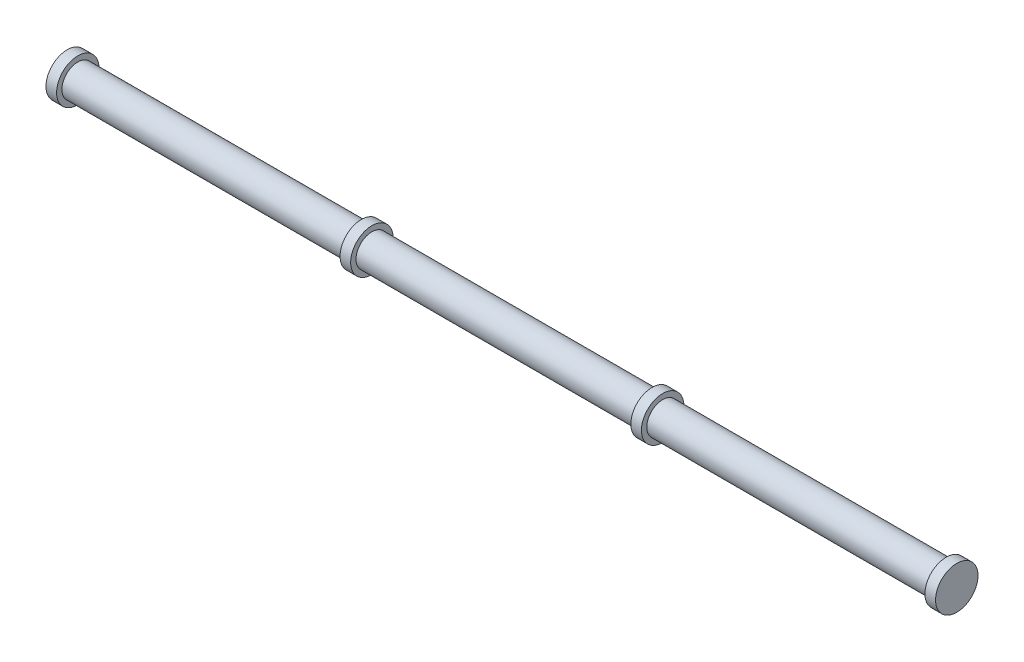
from build123d import *

# Parameters (mm, degrees)
SKETCH1_R           = 7.5
BOSS_EXTRUDE1_DEPTH = 204.47
SKETCH2_R           = 10
BOSS_EXTRUDE2_DEPTH = 5
SKETCH3_R           = 10
BOSS_EXTRUDE3_DEPTH = 2.5
SKETCH4_R           = 10
BOSS_EXTRUDE4_DEPTH = 2.5


with BuildPart() as part:
    # Sketch1 → Boss-Extrude1 (new body, symmetric)
    with BuildSketch(Plane(origin=(0, 0, 0), x_dir=(0, 0, -1), z_dir=(1, 0, 0))):
        Circle(SKETCH1_R)
    extrude(amount=BOSS_EXTRUDE1_DEPTH, both=True)


with BuildPart() as body_2:
    # Sketch2 → Boss-Extrude2 (new body)
    with BuildSketch(Plane(origin=(204.47, 0, 0), x_dir=(0, 0, -1), z_dir=(1, 0, 0))):
        Circle(SKETCH2_R)
    extrude(amount=BOSS_EXTRUDE2_DEPTH)


with BuildPart() as body_3:
    # Mirror1: mirrored copy
    add(body_2.part.mirror(Plane(origin=(0, 0, 0), x_dir=(0, 0, 1), z_dir=(1, 0, 0))))

    # Combine1: union body 2, part
    add(body_2.part)
    add(part.part)

    # Sketch3 → Boss-Extrude3 (add, symmetric)
    with BuildSketch(Plane(origin=(-68.469999966, 0, 0), x_dir=(0, 0, -1), z_dir=(1, 0, 0))):
        Circle(SKETCH3_R)
    extrude(amount=BOSS_EXTRUDE3_DEPTH, both=True)

    # Sketch4 → Boss-Extrude4 (add, symmetric)
    with BuildSketch(Plane.ZY.offset(-68.469999966)):
        Circle(SKETCH4_R)
    extrude(amount=BOSS_EXTRUDE4_DEPTH, both=True)


solid = body_3.part
